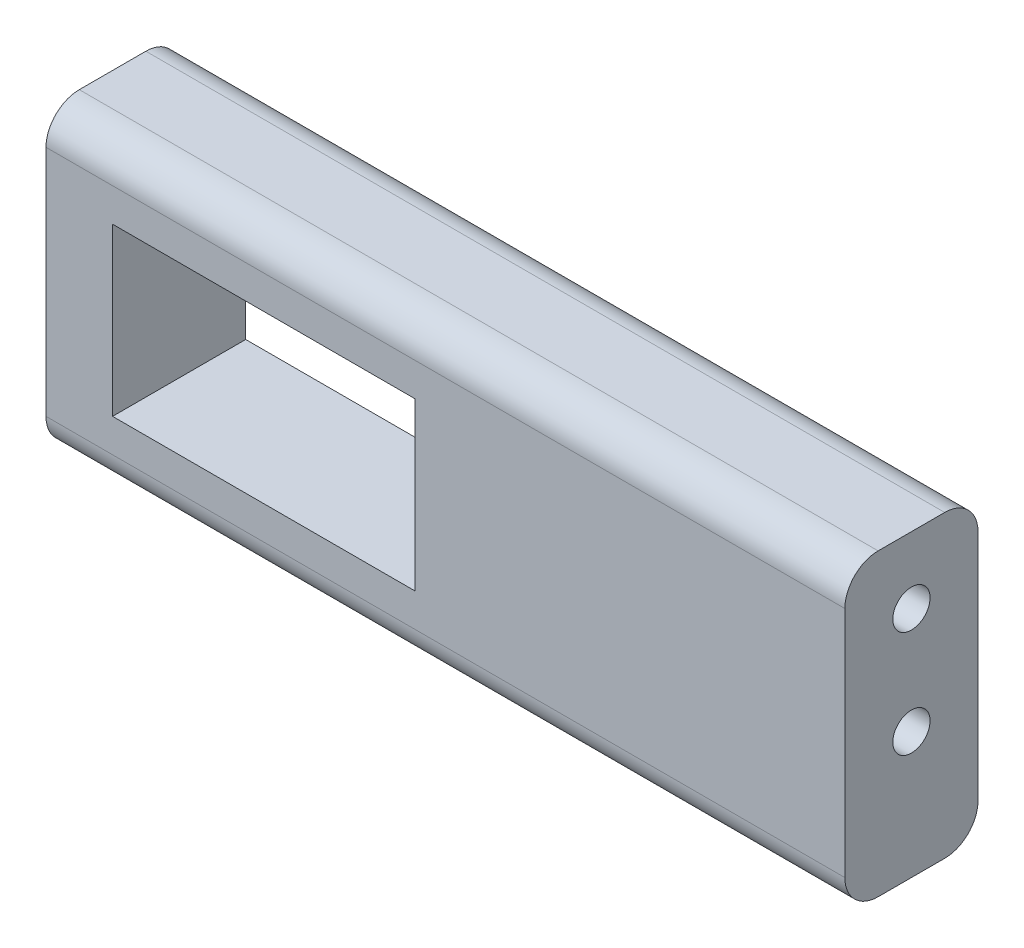
from build123d import *

# Parameters (mm, degrees)
ESBO_O1_W                = 60
ESBO_O1_H                = 22.5
ESBO_O1_W_2              = 22.7
ESBO_O1_H_2              = 12.5
RESSALTO_EXTRUS_O1_DEPTH = 10
ESBO_O3_R                = 1.4
CORTE_EXTRUS_O2_DEPTH    = 20
ESBO_O4_R                = 1.4
CORTE_EXTRUS_O3_DEPTH    = 3
FILETE1_R                = 2.5


with BuildPart() as part:
    # Esboço1 → Ressalto-extrusão1 (new body)
    with BuildSketch(Plane.XY):
        with Locations((14.794474124, 1.507916667)):
            Rectangle(ESBO_O1_W, ESBO_O1_H)
        with Locations((1.144474124, 1.507916667)):
            Rectangle(ESBO_O1_W_2, ESBO_O1_H_2, mode=Mode.SUBTRACT)
    extrude(amount=RESSALTO_EXTRUS_O1_DEPTH)

    # Esboço3 → Corte-extrusão2 (cut)
    with BuildSketch(Plane(origin=(44.794474124, 0, 0), x_dir=(0, 0, -1), z_dir=(1, 0, 0))):
        with Locations((-5, 7.757916667)):
            Circle(ESBO_O3_R)
        with Locations((-5, -0.242083333)):
            Circle(ESBO_O3_R)
    extrude(amount=-CORTE_EXTRUS_O2_DEPTH, mode=Mode.SUBTRACT)

    # Esboço4 → Corte-extrusão3 (cut)
    with BuildSketch(Plane.ZY.offset(15.205525876)):
        with Locations((5, 7.757916667)):
            Circle(ESBO_O4_R)
        with Locations((5, -0.242083333)):
            Circle(ESBO_O4_R)
    extrude(amount=-CORTE_EXTRUS_O3_DEPTH, mode=Mode.SUBTRACT)

    # Filete1
    filete1_edges = [part.edges().sort_by_distance(p)[0] for p in [
        (14.794474124, 12.757916667, 10),
        (14.794474124, 12.757916667, 0),
        (14.794474124, -9.742083333, 0),
        (14.794474124, -9.742083333, 10),
    ]]
    fillet(filete1_edges, radius=FILETE1_R)


solid = part.part
